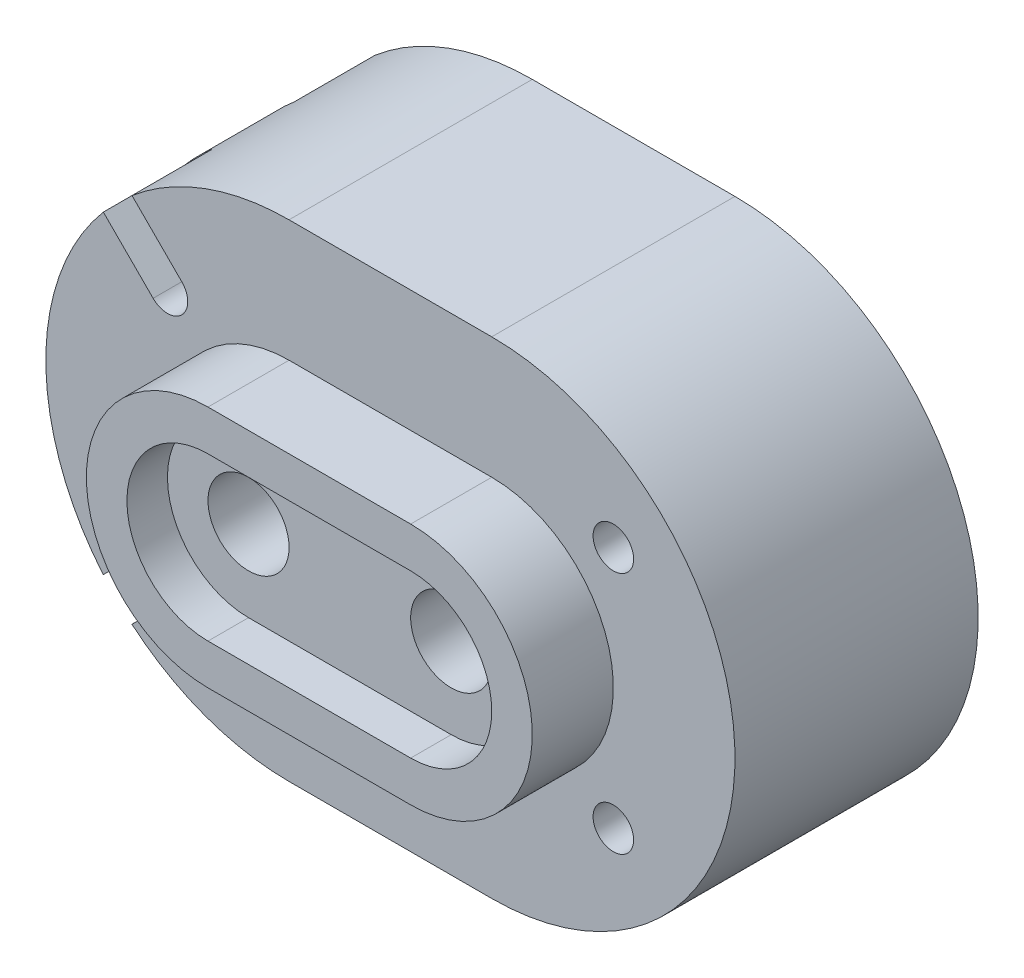
from build123d import *

# Parameters (mm, degrees)
BOSS_EXTRUDE3_DEPTH = 30
BOSS_EXTRUDE4_DEPTH = 10
CUT_EXTRUDE1_DEPTH  = 5
SKETCH5_R           = 5
CUT_EXTRUDE2_DEPTH  = 122
SKETCH6_R           = 2.5
CUT_EXTRUDE4_DEPTH  = 10
CUT_EXTRUDE9_DEPTH  = 10
SKETCH9_R           = 2.5
BOSS_EXTRUDE5_DEPTH = 1.5
CUT_EXTRUDE10_DEPTH = 30
CUT_EXTRUDE11_DEPTH = 15


with BuildPart() as part:
    # Sketch1 → Boss-Extrude3 (new body)
    with BuildSketch(Plane.XY):
        with BuildLine():
            Line((0, 0), (-25, 0))
            ThreePointArc((-25, 0), (-55, 30), (-25, 60))
            Line((-25, 60), (0, 60))
            ThreePointArc((0, 60), (30, 30), (0, 0))
        make_face()
    extrude(amount=BOSS_EXTRUDE3_DEPTH)

    # Sketch3 → Boss-Extrude4 (add)
    with BuildSketch(Plane.XY.offset(30)):
        with BuildLine():
            Line((-25, 45), (0, 45))
            ThreePointArc((0, 45), (15, 30), (0, 15))
            Line((0, 15), (-25, 15))
            ThreePointArc((-25, 15), (-40, 30), (-25, 45))
        make_face()
    extrude(amount=BOSS_EXTRUDE4_DEPTH)

    # Sketch4 → Cut-Extrude1 (cut)
    with BuildSketch(Plane.XY.offset(40)):
        with BuildLine():
            Line((-25, 40), (0, 40))
            ThreePointArc((0, 40), (10, 30), (0, 20))
            Line((0, 20), (-25, 20))
            ThreePointArc((-25, 20), (-35, 30), (-25, 40))
        make_face()
    extrude(amount=-CUT_EXTRUDE1_DEPTH, mode=Mode.SUBTRACT)

    # Sketch5 → Cut-Extrude2 (cut)
    with BuildSketch(Plane.XY.offset(35)):
        with Locations((-25, 30)):
            Circle(SKETCH5_R)
        with Locations((0, 30)):
            Circle(SKETCH5_R)
    extrude(amount=-CUT_EXTRUDE2_DEPTH, mode=Mode.SUBTRACT)

    # Sketch6 → Cut-Extrude4 (cut)
    with BuildSketch(Plane.XY.offset(30)):
        with Locations((15, 45)):
            Circle(SKETCH6_R)
        with Locations((15, 15)):
            Circle(SKETCH6_R)
    extrude(amount=-CUT_EXTRUDE4_DEPTH, mode=Mode.SUBTRACT)

    # Sketch7 → Cut-Extrude9 (cut)
    with BuildSketch(Plane.XY.offset(30)):
        with BuildLine():
            Line((-47.90718511, 49.371651204), (-41.767766953, 43.232233047))
            ThreePointArc((-41.767766953, 43.232233047), (-38.232233047, 43.232233047), (-38.232233047, 46.767766953))
            Line((-38.232233047, 46.767766953), (-44.371651204, 52.90718511))
            ThreePointArc((-44.371651204, 52.90718511), (-46.213203436, 51.213203436), (-47.90718511, 49.371651204))
        make_face()
        with BuildLine():
            Line((-41.768792046, 16.766741265), (-47.914964434, 10.637551678))
            ThreePointArc((-47.914964434, 10.637551678), (-46.221723462, 8.795320015), (-44.380852806, 7.100599473))
            Line((-44.380852806, 7.100599473), (-38.234680419, 13.229789059))
            ThreePointArc((-38.234680419, 13.229789059), (-38.231523045, 16.767056665), (-41.768792046, 16.766741265))
        make_face()
    cut_extrude9 = extrude(amount=-CUT_EXTRUDE9_DEPTH, mode=Mode.SUBTRACT)

    # Sketch9 → Boss-Extrude5 (add)
    with BuildSketch(Plane.XY.offset(20)):
        with Locations((-40, 45)):
            Circle(SKETCH9_R)
        with Locations((-40, 15)):
            Circle(SKETCH9_R)
    extrude(amount=BOSS_EXTRUDE5_DEPTH)

    # Mirror1: Cut-Extrude9 across plane
    add(cut_extrude9.mirror(Plane.XY.offset(15)), mode=Mode.SUBTRACT)

    # Sketch10 → Cut-Extrude10 (cut)
    with BuildSketch(Plane.XY.offset(21.5)):
        with BuildLine():
            ThreePointArc((-38.232233047, 46.767766953), (-41.767766953, 46.767766953), (-41.767766953, 43.232233047))
            ThreePointArc((-41.767766953, 43.232233047), (-38.232233047, 43.232233047), (-38.232233047, 46.767766953))
        make_face()
        with BuildLine():
            ThreePointArc((-41.768792046, 16.766741265), (-41.768476955, 13.232943335), (-38.234680419, 13.229789059))
            ThreePointArc((-38.234680419, 13.229789059), (-38.231523045, 16.767056665), (-41.768792046, 16.766741265))
        make_face()
    extrude(amount=-CUT_EXTRUDE10_DEPTH, mode=Mode.SUBTRACT)

    # Sketch11 → Cut-Extrude11 (cut)
    with BuildSketch(Plane(origin=(0, 0, 0), x_dir=(-1, 0, 0), z_dir=(0, 0, -1))):
        with BuildLine():
            Line((0, 40), (25, 40))
            ThreePointArc((25, 40), (35, 30), (25, 20))
            Line((25, 20), (0, 20))
            ThreePointArc((0, 20), (-10, 30), (0, 40))
        make_face()
    extrude(amount=-CUT_EXTRUDE11_DEPTH, mode=Mode.SUBTRACT)


solid = part.part
